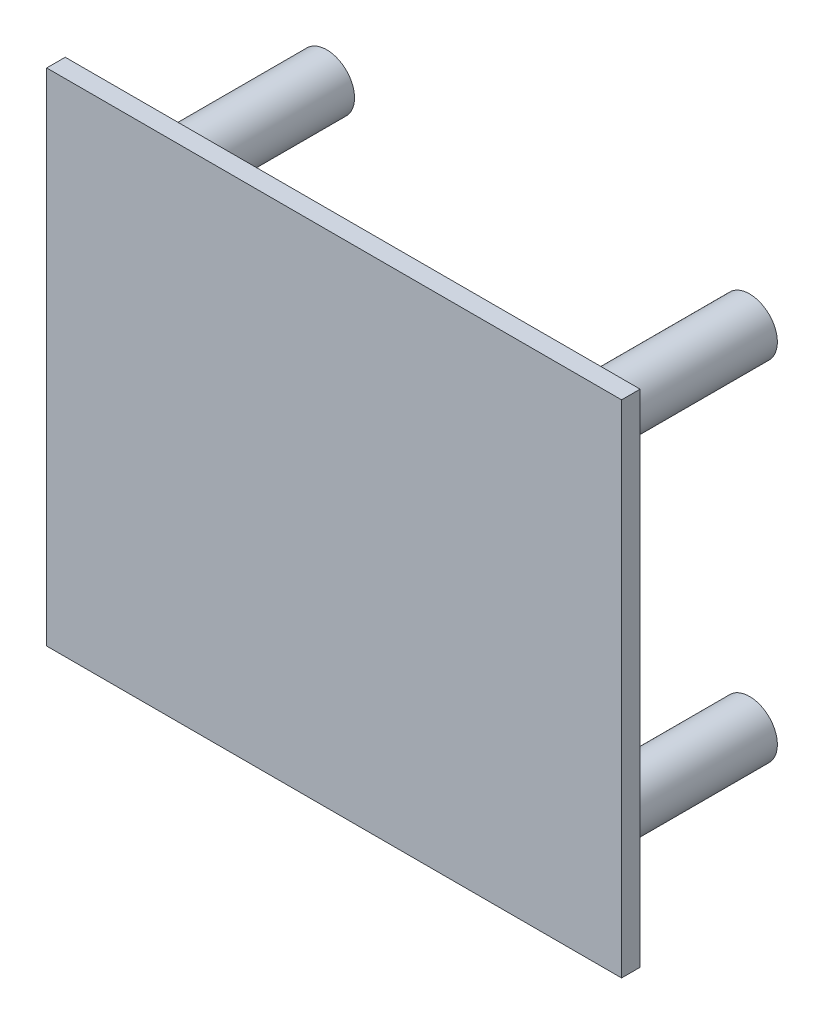
from build123d import *

# Parameters (mm, degrees)
SKETCH1_W               = 31
SKETCH1_H               = 27
BOSS_EXTRUDE1_DEPTH     = 1
SKETCH2_R               = 1.5
BOSS_EXTRUDE2_DEPTH     = 10
MIRROR2_COPY_1_SKETCH_R = 1.5
MIRROR2_COPY_1_DEPTH    = 10


with BuildPart() as part:
    # Sketch1 → Boss-Extrude1 (new body)
    with BuildSketch(Plane.XY):
        Rectangle(SKETCH1_W, SKETCH1_H)
    extrude(amount=BOSS_EXTRUDE1_DEPTH)

    # Sketch2 → Boss-Extrude2 (add)
    with BuildSketch(Plane(origin=(0, 0, 0), x_dir=(-1, 0, 0), z_dir=(0, 0, -1))):
        with Locations((-11.4, -9.4)):
            Circle(SKETCH2_R)
    boss_extrude2 = extrude(amount=BOSS_EXTRUDE2_DEPTH)

    # Mirror1: Boss-Extrude2 across plane
    add(boss_extrude2.mirror(Plane.ZX))

    # Mirror2: Boss-Extrude2 across plane
    add(boss_extrude2.mirror(Plane(origin=(0, 0, 0), x_dir=(0, 0, 1), z_dir=(1, 0, 0))))

    # Mirror2 copy 1 sketch → Mirror2 copy 1 (add)
    with BuildSketch(Plane(origin=(0, 0, 0), x_dir=(1, 0, 0), z_dir=(0, 0, -1))):
        with Locations((-11.4, -9.4)):
            Circle(MIRROR2_COPY_1_SKETCH_R)
    extrude(amount=MIRROR2_COPY_1_DEPTH)


solid = part.part
